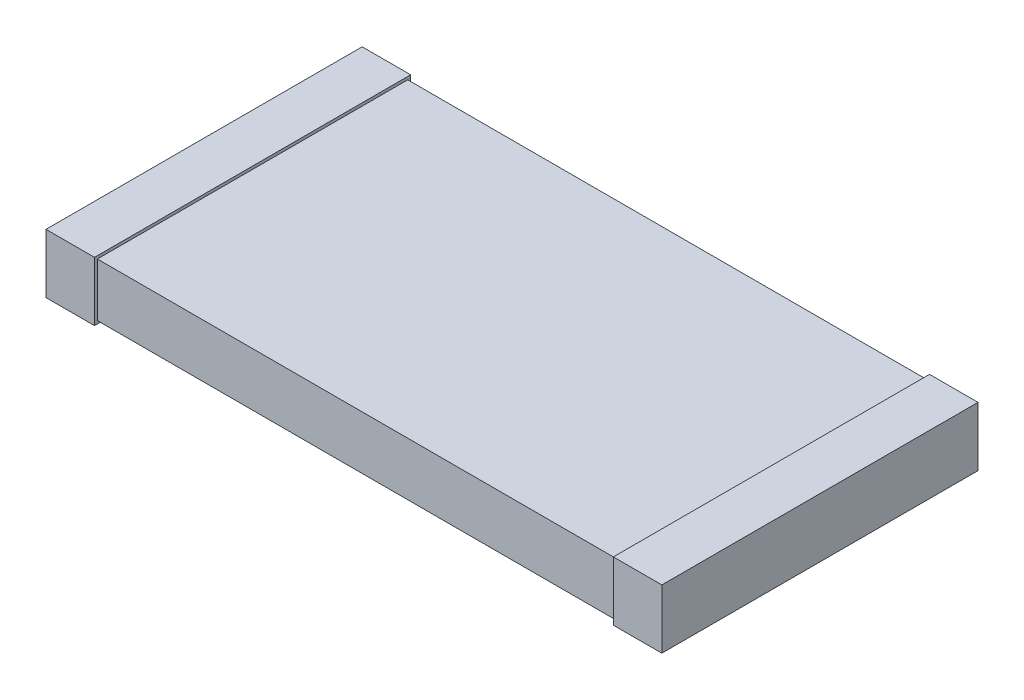
from build123d import *

# Parameters (mm, degrees)
SKETCH1_W           = 6.35
SKETCH1_H           = 3.2
EXTRUDE1_DEPTH      = 0.55
SKETCH2_W           = 0.5
SKETCH2_H           = 0.61
EXTRUDE2_DEPTH      = 1.63
EXTRUDE2_DEPTH_BACK = 1.63


with BuildPart() as part:
    # Sketch1 → Extrude1 (new body)
    with BuildSketch(Plane(origin=(0, 0, 0), x_dir=(1, 0, 0), z_dir=(0, 1, 0))):
        Rectangle(SKETCH1_W, SKETCH1_H)
    extrude(amount=EXTRUDE1_DEPTH)

    # Sketch2 → Extrude2 (add, two sides)
    with BuildSketch(Plane.XY) as extrude2_sk:
        with Locations((-2.925, 0.275)):
            Rectangle(SKETCH2_W, SKETCH2_H)
        with Locations((2.925, 0.275)):
            Rectangle(SKETCH2_W, SKETCH2_H)
    extrude(amount=EXTRUDE2_DEPTH)
    extrude(extrude2_sk.sketch, amount=-EXTRUDE2_DEPTH_BACK)


solid = part.part
